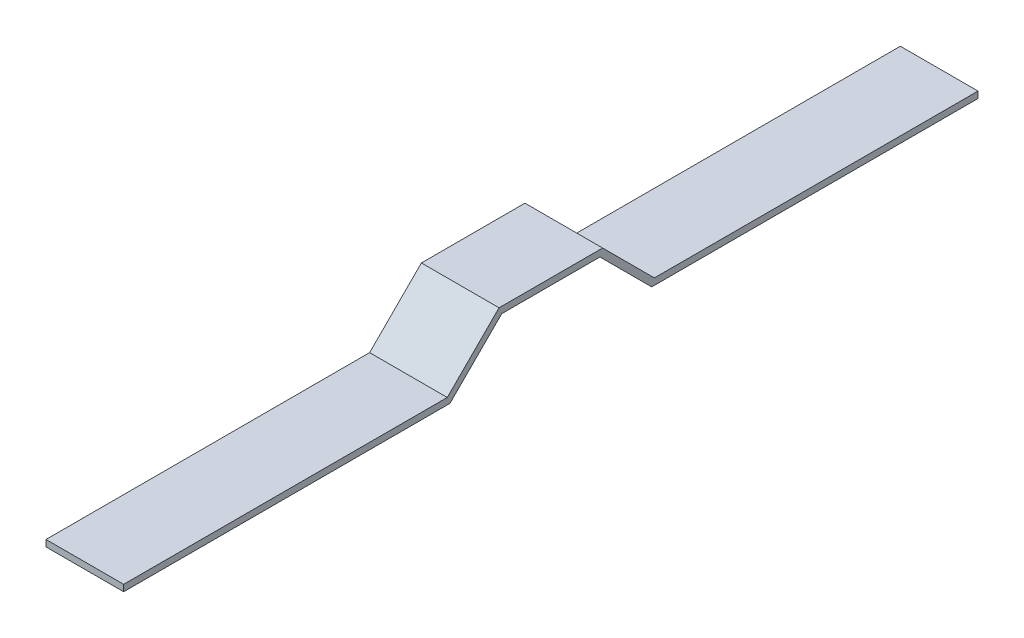
from build123d import *

# Parameters (mm, degrees)
BOSS_EXTRUDE1_DEPTH = 38.1


with BuildPart() as part:
    # Sketch1 → Boss-Extrude1 (new body)
    with BuildSketch(Plane(origin=(0, 0, 0), x_dir=(0, 0, -1), z_dir=(1, 0, 0))):
        Polygon((-145.44109589, -11.830136986), (13.30890411, -11.830136986), (38.70890411, 13.569863014), (89.50890411, 13.569863014), (114.90890411, -11.830136986), (273.65890411, -11.830136986), (273.65890411, -15.005136986), (113.593776049, -15.005136986), (88.193776049, 10.394863014), (40.02403217, 10.394863014), (14.62403217, -15.005136986), (-145.44109589, -15.005136986), align=None)
    extrude(amount=BOSS_EXTRUDE1_DEPTH)


solid = part.part
